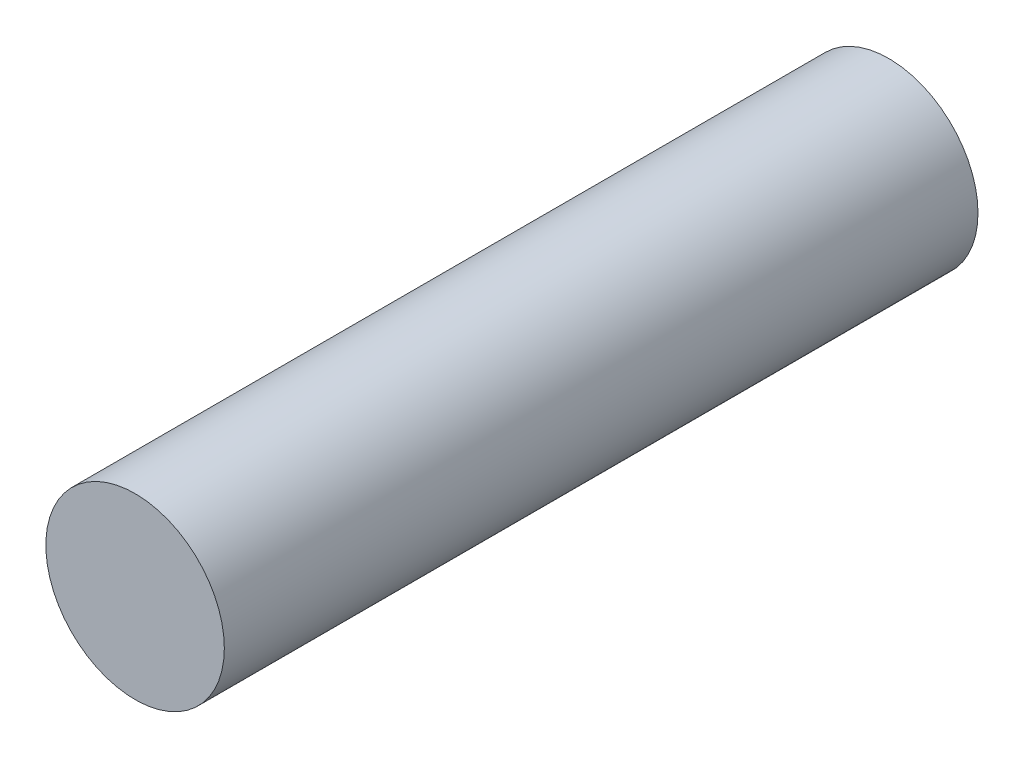
from build123d import *

# Parameters (mm, degrees)
SKETCH1_R           = 9
BOSS_EXTRUDE1_DEPTH = 76


with BuildPart() as part:
    # Sketch1 → Boss-Extrude1 (new body)
    with BuildSketch(Plane.XY):
        Circle(SKETCH1_R)
    extrude(amount=BOSS_EXTRUDE1_DEPTH)


solid = part.part
